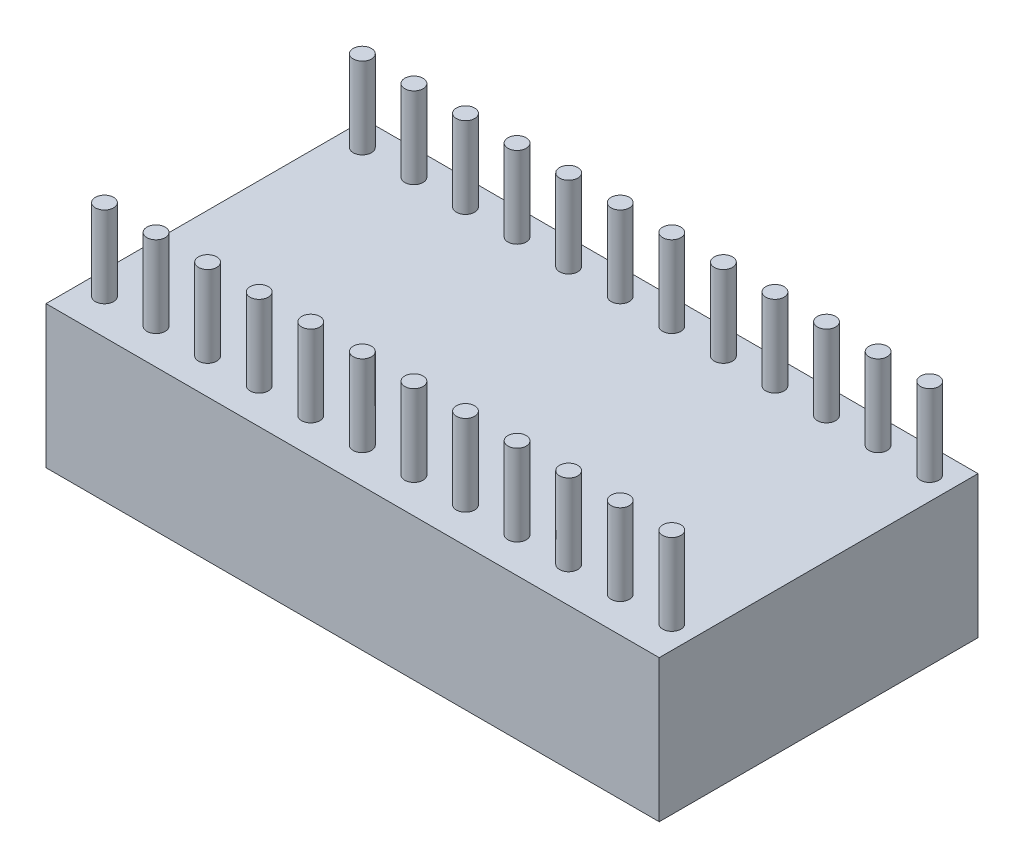
from build123d import *

# Parameters (mm, degrees)
SKETCH1_W           = 30.2
SKETCH1_H           = 15.7
BOSS_EXTRUDE1_DEPTH = 7
SKETCH2_R           = 0.45
BOSS_EXTRUDE2_DEPTH = 4


with BuildPart() as part:
    # Sketch1 → Boss-Extrude1 (new body)
    with BuildSketch(Plane(origin=(0, 0, 0), x_dir=(1, 0, 0), z_dir=(0, 1, 0))):
        with Locations((15.1, -7.85)):
            Rectangle(SKETCH1_W, SKETCH1_H)
    extrude(amount=BOSS_EXTRUDE1_DEPTH)

    # Sketch2 → Boss-Extrude2 (add)
    with BuildSketch(Plane(origin=(0, 7, 0), x_dir=(1, 0, 0), z_dir=(0, 1, 0))):
        with Locations((1.13, -1.25)):
            Circle(SKETCH2_R)
        with Locations((3.67, -1.25)):
            Circle(SKETCH2_R)
        with Locations((6.21, -1.25)):
            Circle(SKETCH2_R)
        with Locations((8.75, -1.25)):
            Circle(SKETCH2_R)
        with Locations((11.29, -1.25)):
            Circle(SKETCH2_R)
        with Locations((13.83, -1.25)):
            Circle(SKETCH2_R)
        with Locations((16.37, -1.25)):
            Circle(SKETCH2_R)
        with Locations((18.91, -1.25)):
            Circle(SKETCH2_R)
        with Locations((21.45, -1.25)):
            Circle(SKETCH2_R)
        with Locations((23.99, -1.25)):
            Circle(SKETCH2_R)
        with Locations((26.53, -1.25)):
            Circle(SKETCH2_R)
        with Locations((29.07, -1.25)):
            Circle(SKETCH2_R)
        with Locations((29.07, -13.95)):
            Circle(SKETCH2_R)
        with Locations((26.53, -13.95)):
            Circle(SKETCH2_R)
        with Locations((23.99, -13.95)):
            Circle(SKETCH2_R)
        with Locations((21.45, -13.95)):
            Circle(SKETCH2_R)
        with Locations((18.91, -13.95)):
            Circle(SKETCH2_R)
        with Locations((16.37, -13.95)):
            Circle(SKETCH2_R)
        with Locations((13.83, -13.95)):
            Circle(SKETCH2_R)
        with Locations((11.29, -13.95)):
            Circle(SKETCH2_R)
        with Locations((8.75, -13.95)):
            Circle(SKETCH2_R)
        with Locations((6.21, -13.95)):
            Circle(SKETCH2_R)
        with Locations((3.67, -13.95)):
            Circle(SKETCH2_R)
        with Locations((1.13, -13.95)):
            Circle(SKETCH2_R)
    extrude(amount=BOSS_EXTRUDE2_DEPTH)


solid = part.part
